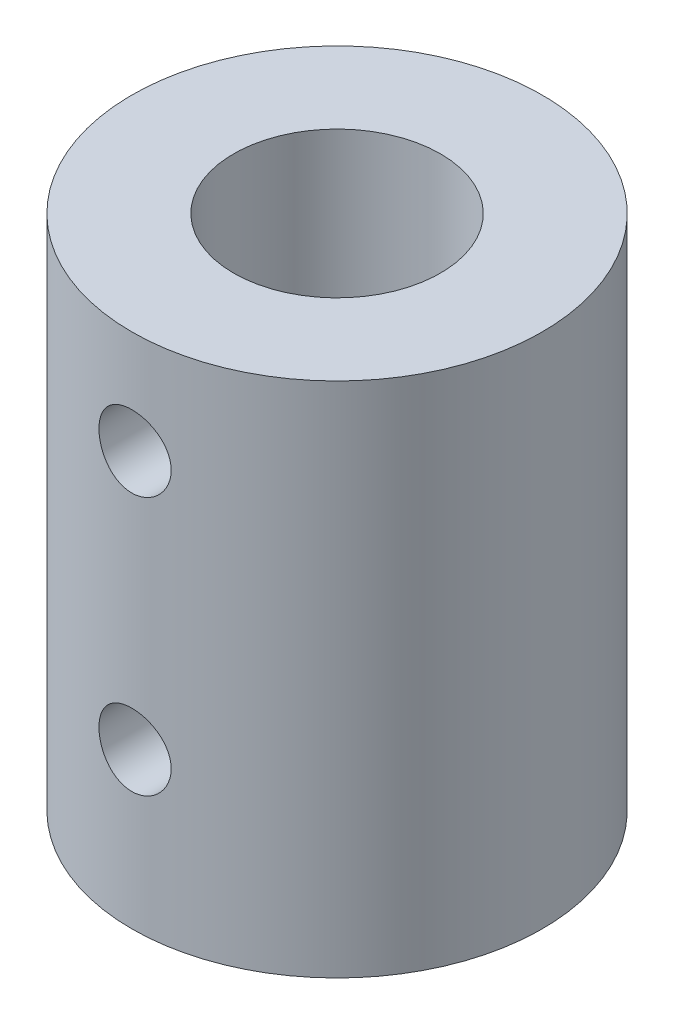
from build123d import *

# Parameters (mm, degrees)
SKETCH2_R           = 7.9375
BOSS_EXTRUDE1_DEPTH = 20
SKETCH3_R           = 4
CUT_EXTRUDE1_DEPTH  = 8
SKETCH4_R           = 3
CUT_EXTRUDE2_DEPTH  = 12
SKETCH6_R           = 1.397
CUT_EXTRUDE3_DEPTH  = 6


with BuildPart() as part:
    # Sketch2 → Boss-Extrude1 (new body)
    with BuildSketch(Plane(origin=(0, 0, 0), x_dir=(1, 0, 0), z_dir=(0, 1, 0))):
        Circle(SKETCH2_R)
    extrude(amount=BOSS_EXTRUDE1_DEPTH)

    # Sketch3 → Cut-Extrude1 (cut)
    with BuildSketch(Plane(origin=(0, 20, 0), x_dir=(1, 0, 0), z_dir=(0, 1, 0))):
        Circle(SKETCH3_R)
    extrude(amount=-CUT_EXTRUDE1_DEPTH, mode=Mode.SUBTRACT)

    # Sketch4 → Cut-Extrude2 (cut)
    with BuildSketch(Plane.XZ):
        Circle(SKETCH4_R)
    extrude(amount=-CUT_EXTRUDE2_DEPTH, mode=Mode.SUBTRACT)

    # Sketch6 → Cut-Extrude3 (cut)
    with BuildSketch(Plane.XY.offset(7.9375)):
        with Locations((0, 6)):
            Circle(SKETCH6_R)
        with Locations((0, 16)):
            Circle(SKETCH6_R)
    extrude(amount=-CUT_EXTRUDE3_DEPTH, mode=Mode.SUBTRACT)


solid = part.part
